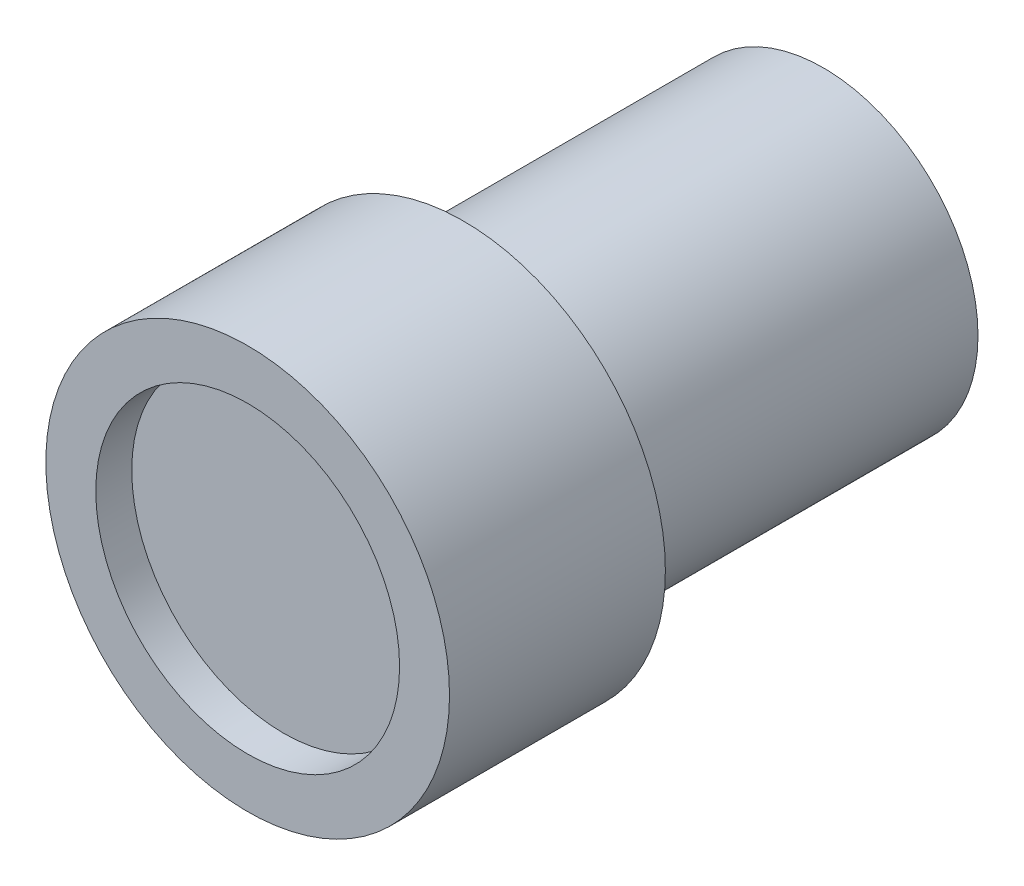
from build123d import *

# Parameters (mm, degrees)
SKETCH1_R      = 5.461
EXTRUDE1_DEPTH = 12.7
SKETCH2_R      = 7.125092069
EXTRUDE2_DEPTH = 7.62
SKETCH3_R      = 5.362383774
EXTRUDE3_DEPTH = 1.27


with BuildPart() as part:
    # Sketch1 → Extrude1 (new body)
    with BuildSketch(Plane.XY):
        Circle(SKETCH1_R)
    extrude(amount=EXTRUDE1_DEPTH)

    # Sketch2 → Extrude2 (add)
    with BuildSketch(Plane.XY.offset(12.7)):
        Circle(SKETCH2_R)
    extrude(amount=EXTRUDE2_DEPTH)

    # Sketch3 → Extrude3 (cut)
    with BuildSketch(Plane.XY.offset(20.32)):
        Circle(SKETCH3_R)
    extrude(amount=-EXTRUDE3_DEPTH, mode=Mode.SUBTRACT)


solid = part.part
